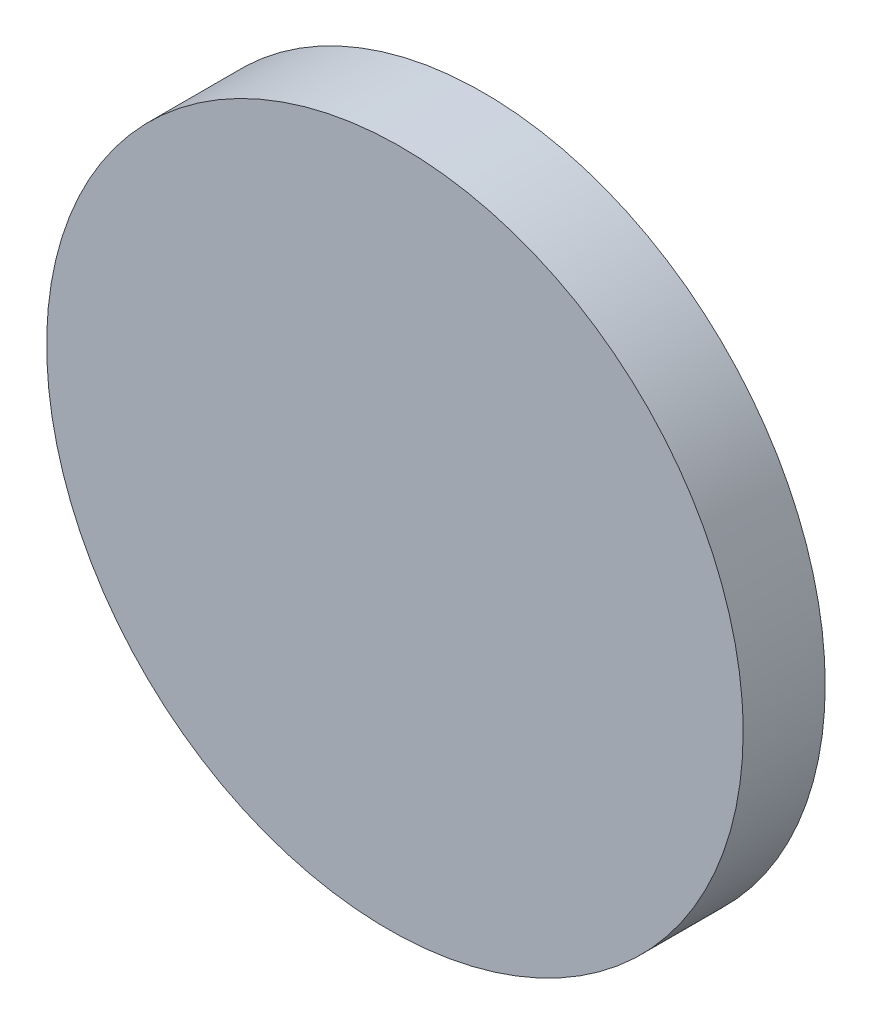
from build123d import *

# Parameters (mm, degrees)
SKETCH_1_R          = 12.5
EXTRUDE_1_DEPTH     = 10
CUT_EXTRUDE_1_DEPTH = 25


with BuildPart() as part:
    # 草图1 → 凸台-拉伸1 (new body)
    with BuildSketch(Plane.XY):
        Circle(SKETCH_1_R)
    extrude(amount=EXTRUDE_1_DEPTH)

    # 草图2 → 切除-拉伸1 (cut, symmetric)
    with BuildSketch(Plane(origin=(0, 0, 0), x_dir=(1, 0, 0), z_dir=(0, 1, 0))):
        Polygon((12.5, -3), (-16.637251363, -3.534027804), (-16.637251363, -14.471860794), (17.771579719, -14.471860794), (17.771579719, -3), align=None)
    extrude(amount=CUT_EXTRUDE_1_DEPTH, both=True, mode=Mode.SUBTRACT)


solid = part.part
